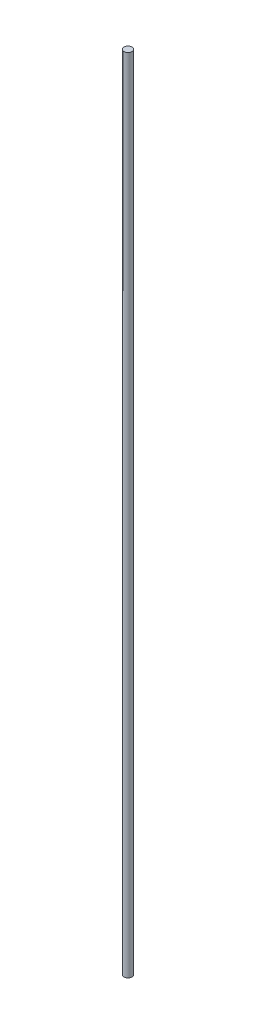
from build123d import *

# Parameters (mm, degrees)
SKETCH1_R           = 20
BOSS_EXTRUDE1_DEPTH = 4000


with BuildPart() as part:
    # Sketch1 → Boss-Extrude1 (new body)
    with BuildSketch(Plane(origin=(0, 0, 0), x_dir=(1, 0, 0), z_dir=(0, 1, 0))):
        Circle(SKETCH1_R)
    extrude(amount=BOSS_EXTRUDE1_DEPTH)


solid = part.part
